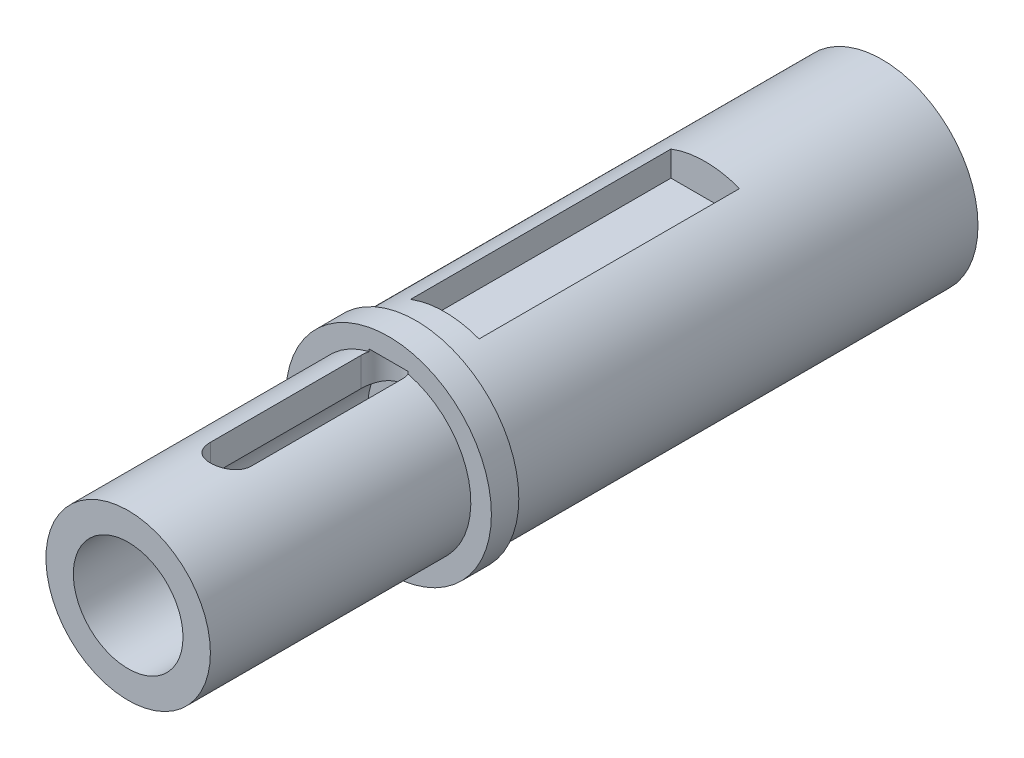
from build123d import *

# Parameters (mm, degrees)
SKETCH1_R           = 7
BOSS_EXTRUDE1_DEPTH = 34
SKETCH2_R           = 7.5
BOSS_EXTRUDE2_DEPTH = 2
SKETCH3_R           = 6
BOSS_EXTRUDE3_DEPTH = 19
SKETCH4_R           = 4
CUT_EXTRUDE1_DEPTH  = 21.5
CUT_EXTRUDE2_REACH  = 15.5
SKETCH6_W           = 5
SKETCH6_H           = 4.6
CUT_EXTRUDE3_DEPTH  = 19


with BuildPart() as part:
    # Sketch1 → Boss-Extrude1 (new body)
    with BuildSketch(Plane.XY):
        Circle(SKETCH1_R)
    extrude(amount=BOSS_EXTRUDE1_DEPTH)

    # Sketch2 → Boss-Extrude2 (add)
    with BuildSketch(Plane.XY.offset(34)):
        Circle(SKETCH2_R)
    extrude(amount=BOSS_EXTRUDE2_DEPTH)

    # Sketch3 → Boss-Extrude3 (add)
    with BuildSketch(Plane.XY.offset(36)):
        Circle(SKETCH3_R)
    extrude(amount=BOSS_EXTRUDE3_DEPTH)

    # Sketch4 → Cut-Extrude1 (cut)
    with BuildSketch(Plane.XY.offset(55)):
        Circle(SKETCH4_R)
    extrude(amount=-CUT_EXTRUDE1_DEPTH, mode=Mode.SUBTRACT)

    # Sketch5 → Cut-Extrude2 (cut, up to next)
    with BuildSketch(Plane(origin=(0, 6, 0), x_dir=(1, 0, 0), z_dir=(0, 1, 0)), mode=Mode.PRIVATE) as cut_extrude2_sk1:
        with BuildLine():
            Line((-1.5, -47.5), (-1.5, -36.5))
            ThreePointArc((-1.5, -36.5), (0, -35), (1.5, -36.5))
            Line((1.5, -36.5), (1.5, -47.5))
            ThreePointArc((1.5, -47.5), (0, -49), (-1.5, -47.5))
        make_face()
    cut_extrude2_tool1 = extrude(cut_extrude2_sk1.sketch, amount=-CUT_EXTRUDE2_REACH, mode=Mode.PRIVATE) & part.part
    add(cut_extrude2_tool1.solids().sort_by_distance((0, 6, 42))[0], mode=Mode.SUBTRACT)

    # Sketch6 → Cut-Extrude3 (cut)
    with BuildSketch(Plane(origin=(0, 0, 31.9), x_dir=(-1, 0, 0), z_dir=(0, 0, -1))):
        with Locations((0, 7)):
            Rectangle(SKETCH6_W, SKETCH6_H)
    extrude(amount=CUT_EXTRUDE3_DEPTH, mode=Mode.SUBTRACT)


solid = part.part
